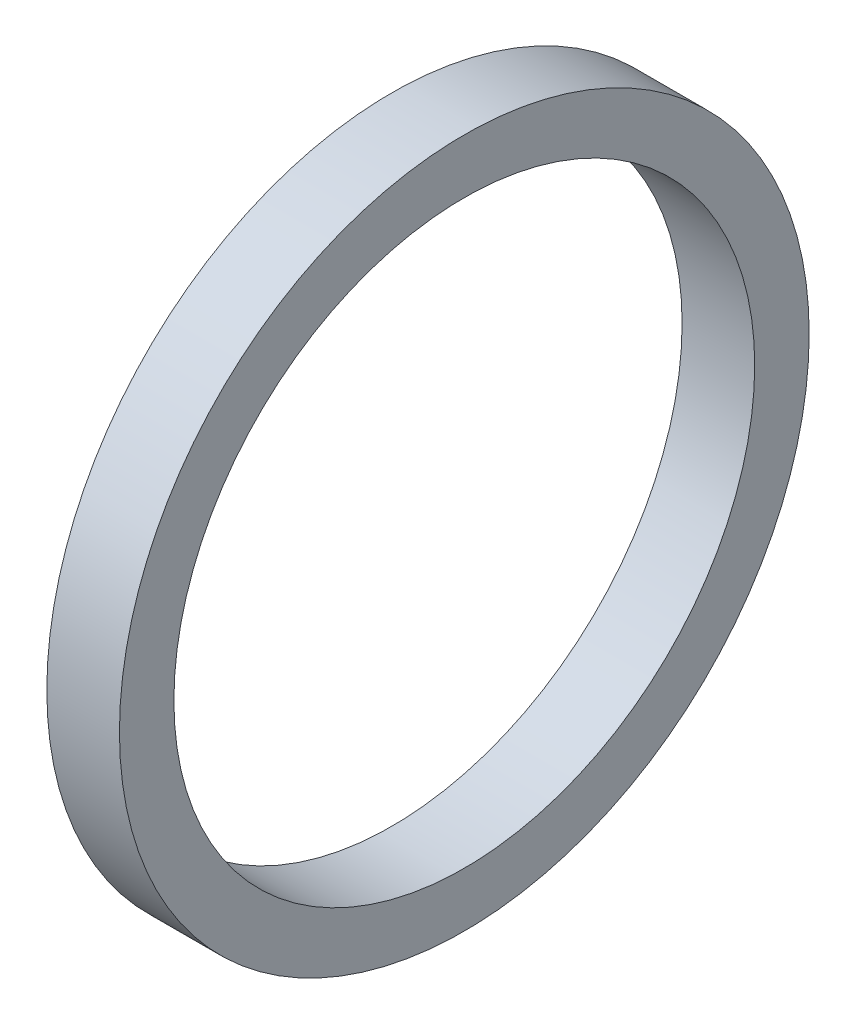
from build123d import *

# Parameters (mm, degrees)
SKETCH_1_W = 4
SKETCH_1_H = 3


with BuildPart() as part:
    # 草图1 → 旋转1 (revolve)
    with BuildSketch(Plane(origin=(0, -928.71077907, 3.029080223), x_dir=(1, 0, 0), z_dir=(0, 0.999994681, -0.00326158))):
        with Locations((4150.913235594, -4935.110639877)):
            Rectangle(SKETCH_1_W, SKETCH_1_H)
    revolve(axis=Axis((4131.913235594, -912.557445345, 4955.613377338), (1, 0, 0)))


solid = part.part
